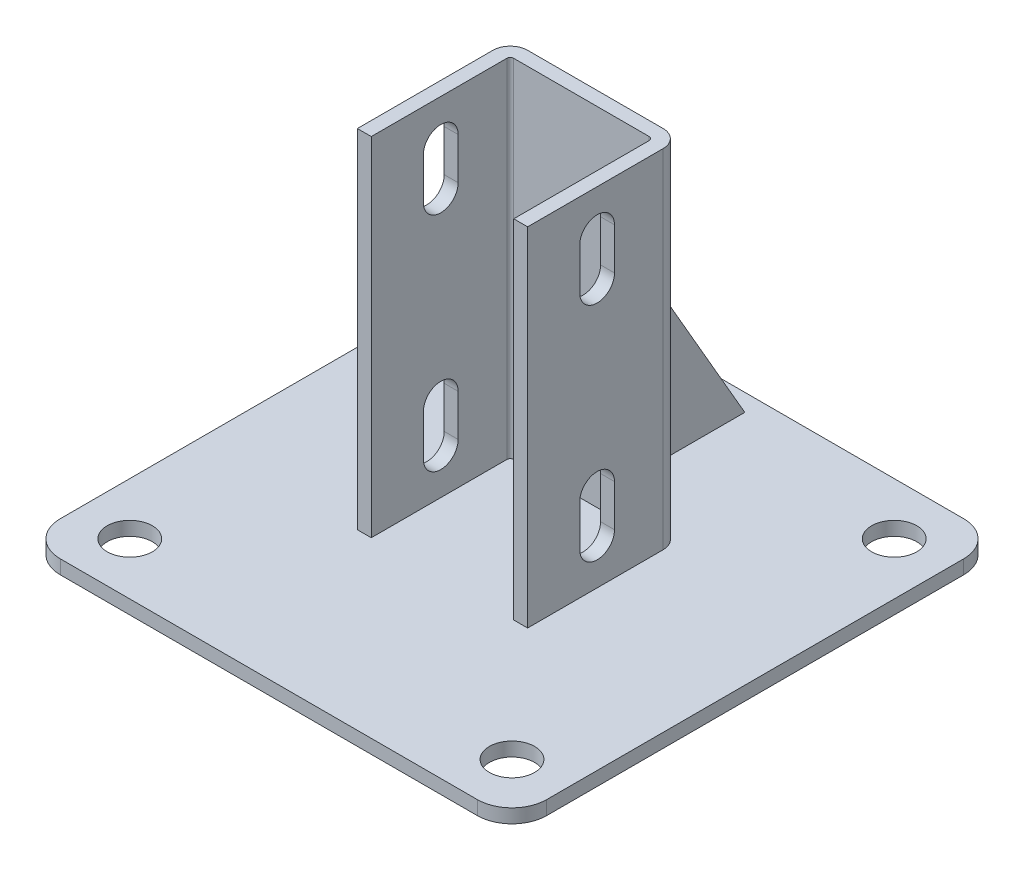
from build123d import *

# Parameters (mm, degrees)
SKETCH_2_W          = 140
SKETCH_2_H          = 140
EXTRUDE_1_DEPTH     = 4
EXTRUDE_1_2_DEPTH   = 100
EXTRUDE_2_DEPTH     = 2
CUT_EXTRUDE_1_DEPTH = 95.5
SKETCH_6_R          = 6.5
CUT_EXTRUDE_2_DEPTH = 5
FILLET_1_R          = 10


with BuildPart() as part:
    # Эскиз2 → Extrude 1 (new body)
    with BuildSketch(Plane(origin=(0, 0, 0), x_dir=(1, 0, 0), z_dir=(0, 1, 0))):
        Rectangle(SKETCH_2_W, SKETCH_2_H)
    extrude(amount=EXTRUDE_1_DEPTH)

    # Эскиз3 → Extrude 1 2 (add)
    with BuildSketch(Plane(origin=(0, 4, 0), x_dir=(1, 0, 0), z_dir=(0, 1, 0))):
        with BuildLine():
            Line((-20.5, -20), (-20.5, 19))
            ThreePointArc((-20.5, 19), (-20.207106781, 19.707106781), (-19.5, 20))
            Line((-19.5, 20), (19.5, 20))
            ThreePointArc((19.5, 20), (20.207106781, 19.707106781), (20.5, 19))
            Line((20.5, 19), (20.5, -20))
            Line((20.5, -20), (24.5, -20))
            Line((24.5, -20), (24.5, 19))
            ThreePointArc((24.5, 19), (23.035533906, 22.535533906), (19.5, 24))
            Line((19.5, 24), (-19.5, 24))
            ThreePointArc((-19.5, 24), (-23.035533906, 22.535533906), (-24.5, 19))
            Line((-24.5, 19), (-24.5, -20))
            Line((-24.5, -20), (-20.5, -20))
        make_face()
    extrude(amount=EXTRUDE_1_2_DEPTH)

    # Эскиз4 → Бобышка-Вытянуть2 (add, symmetric)
    with BuildSketch(Plane(origin=(0, 0, 0), x_dir=(0, 0, -1), z_dir=(1, 0, 0))):
        Polygon((24, 75.01408311), (65, 4), (24, 4), align=None)
    extrude(amount=EXTRUDE_2_DEPTH, both=True)

    # Эскиз5 → Вырез-Вытянуть1 (cut, through all)
    with BuildSketch(Plane(origin=(24.5, 0, 0), x_dir=(0, 0, -1), z_dir=(1, 0, 0))):
        with BuildLine():
            Line((5, 92), (5, 80))
            ThreePointArc((5, 80), (0, 75), (-5, 80))
            Line((-5, 80), (-5, 92))
            ThreePointArc((-5, 92), (0, 97), (5, 92))
        make_face()
        with BuildLine():
            Line((5, 28), (5, 16))
            ThreePointArc((5, 16), (0, 11), (-5, 16))
            Line((-5, 16), (-5, 28))
            ThreePointArc((-5, 28), (0, 33), (5, 28))
        make_face()
    extrude(amount=-CUT_EXTRUDE_1_DEPTH, mode=Mode.SUBTRACT)

    # Эскиз6 → Вырез-Вытянуть2 (cut, through all)
    with BuildSketch(Plane(origin=(0, 4, 0), x_dir=(1, 0, 0), z_dir=(0, 1, 0))):
        with Locations(Location((-55, 55, 0), (0, 0, 270))):  # turned: the seam where the file's is
            Circle(SKETCH_6_R)
        with Locations(Location((-55, -55, 0), (0, 0, 270))):  # turned: the seam where the file's is
            Circle(SKETCH_6_R)
        with Locations(Location((55, 55, 0), (0, 0, 270))):  # turned: the seam where the file's is
            Circle(SKETCH_6_R)
        with Locations(Location((55, -55, 0), (0, 0, 270))):  # turned: the seam where the file's is
            Circle(SKETCH_6_R)
    extrude(amount=-CUT_EXTRUDE_2_DEPTH, mode=Mode.SUBTRACT)

    # Скругление1
    fillet_1_edges = [part.edges().sort_by_distance(p)[0] for p in [
        (70, 2, 70),
        (-70, 2, 70),
        (-70, 2, -70),
        (70, 2, -70),
    ]]
    fillet(fillet_1_edges, radius=FILLET_1_R)


solid = part.part
